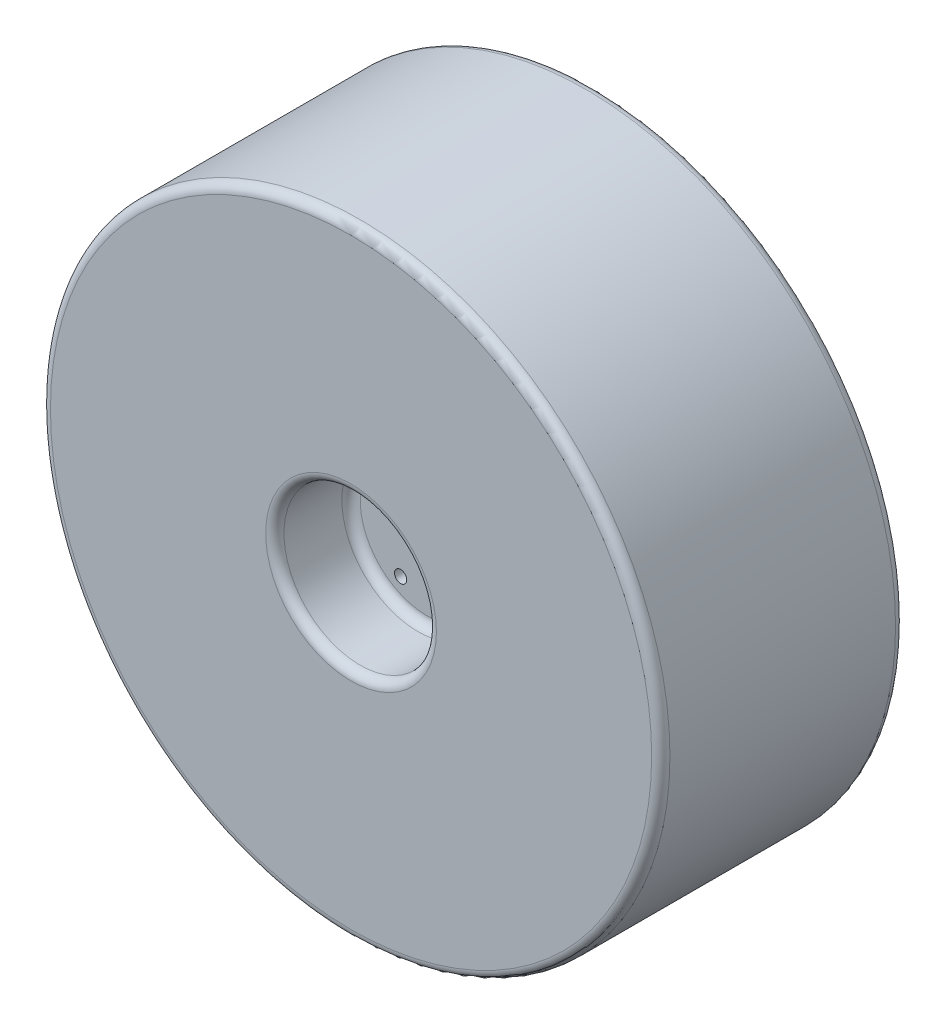
from build123d import *

# Parameters (mm, degrees)
SKETCH1_R           = 203.2
BOSS_EXTRUDE2_DEPTH = 160
SKETCH3_R           = 50
CUT_EXTRUDE1_DEPTH  = 50
SKETCH4_R           = 50
CUT_EXTRUDE2_DEPTH  = 50
FILLET1_R           = 6
SKETCH5_R           = 4
CUT_EXTRUDE3_DEPTH  = 45
SKETCH6_R           = 6.5
CUT_EXTRUDE4_DEPTH  = 111


with BuildPart() as part:
    # Sketch1 → Boss-Extrude2 (new body)
    with BuildSketch(Plane.XY):
        Circle(SKETCH1_R)
    extrude(amount=BOSS_EXTRUDE2_DEPTH)

    # Sketch3 → Cut-Extrude1 (cut)
    with BuildSketch(Plane.XY.offset(160)):
        Circle(SKETCH3_R)
    extrude(amount=-CUT_EXTRUDE1_DEPTH, mode=Mode.SUBTRACT)

    # Sketch4 → Cut-Extrude2 (cut)
    with BuildSketch(Plane(origin=(0, 0, 0), x_dir=(-1, 0, 0), z_dir=(0, 0, -1))):
        Circle(SKETCH4_R)
    extrude(amount=-CUT_EXTRUDE2_DEPTH, mode=Mode.SUBTRACT)

    # Fillet1
    fillet1_edges = [part.edges().sort_by_distance(p)[0] for p in [
        (50, 0, 50),
        (50, 0, 0),
        (-203.2, 0, 0),
        (-203.2, 0, 160),
        (-50, 0, 110),
        (-50, 0, 160),
    ]]
    fillet(fillet1_edges, radius=FILLET1_R)

    # Sketch5 → Cut-Extrude3 (cut)
    with BuildSketch(Plane.XY.offset(110)):
        with Locations((35, 0)):
            Circle(SKETCH5_R)
        with Locations((-17.5, -30.310889132)):
            Circle(SKETCH5_R)
        with Locations((-17.5, 30.310889132)):
            Circle(SKETCH5_R)
    extrude(amount=-CUT_EXTRUDE3_DEPTH, mode=Mode.SUBTRACT)

    # Sketch6 → Cut-Extrude4 (cut, through all)
    with BuildSketch(Plane.XY.offset(110)):
        Circle(SKETCH6_R)
    extrude(amount=-CUT_EXTRUDE4_DEPTH, mode=Mode.SUBTRACT)


solid = part.part
